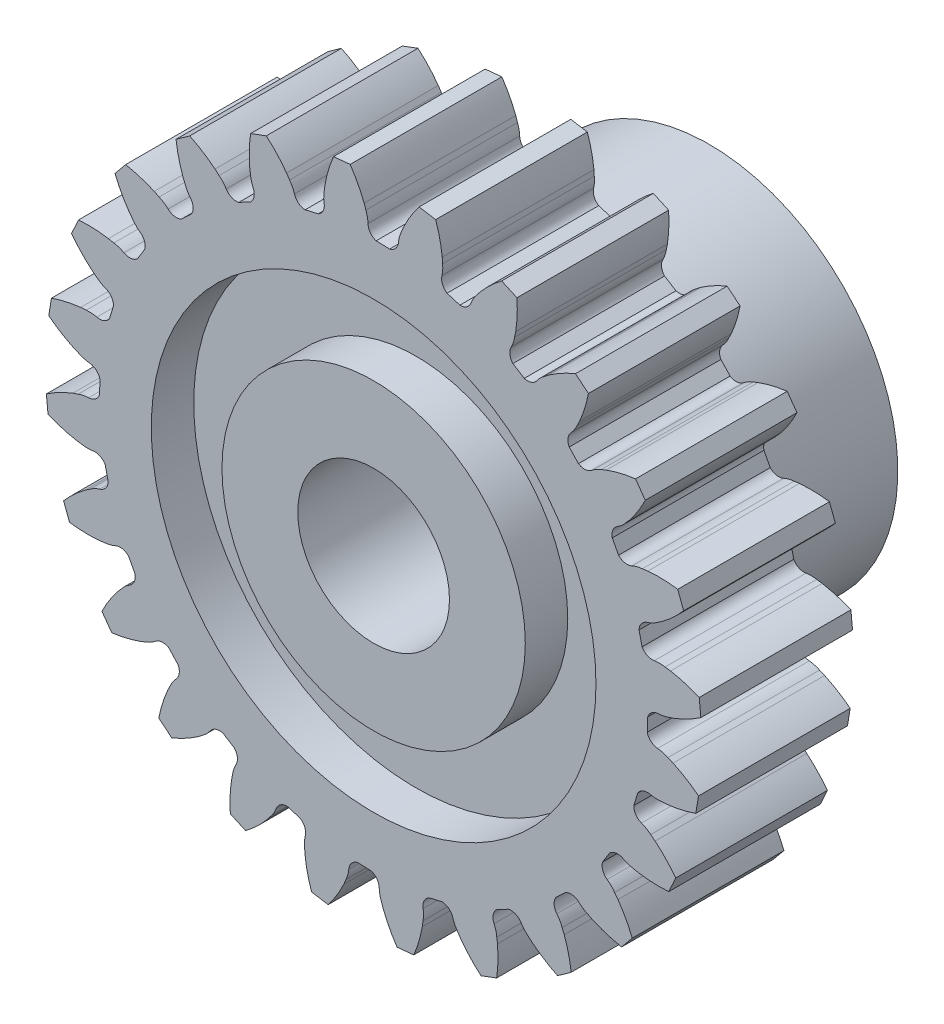
from build123d import *

# Parameters (mm, degrees)
MODEL_R             = 3.175
BOSS_EXTRUDE1_DEPTH = 6.35
SKETCH2_R           = 9.3091
SKETCH2_R_2         = 6.35
CUT_EXTRUDE1_DEPTH  = 1.778
SKETCH3_R           = 9.3091
CUT_EXTRUDE2_DEPTH  = 1.778
SKETCH4_R           = 7.8994
SKETCH4_R_2         = 3.175
BOSS_EXTRUDE2_DEPTH = 9.4742


with BuildPart() as part:
    # Model → Boss-Extrude1 (new body)
    with BuildSketch(Plane.XY):
        with BuildLine():
            Line((68.8088615, 76.100413011), (68.949845876, 76.283537584))
            ThreePointArc((68.949845876, 76.283537584), (69.380371663, 76.740716027), (69.860317621, 77.145705481))
            Line((69.860317621, 77.145705481), (70.499439483, 76.85531076))
            ThreePointArc((70.499439483, 76.85531076), (70.510066782, 76.227411927), (70.448876379, 75.602411432))
            Line((70.448876379, 75.602411432), (70.403671608, 75.375769654))
            ThreePointArc((70.403671608, 75.375769654), (70.351079825, 75.157164123), (70.262296035, 74.950592797))
            ThreePointArc((70.262296035, 74.950592797), (70.203912532, 74.656552674), (70.329513662, 74.384353958))
            Line((70.329513662, 74.384353958), (70.807027179, 74.086709545))
            ThreePointArc((70.807027179, 74.086709545), (71.106721458, 74.093816324), (71.345001962, 74.275721706))
            ThreePointArc((71.345001962, 74.275721706), (71.491362462, 74.446407496), (71.664470214, 74.58989593))
            Line((71.664470214, 74.58989593), (71.848050446, 74.730279746))
            ThreePointArc((71.848050446, 74.730279746), (72.382236404, 75.060455264), (72.950651667, 75.327428298))
            Line((72.950651667, 75.327428298), (73.492829056, 74.88151044))
            ThreePointArc((73.492829056, 74.88151044), (73.340582062, 74.272256193), (73.11971464, 73.684389315))
            Line((73.11971464, 73.684389315), (73.01739474, 73.477170567))
            ThreePointArc((73.01739474, 73.477170567), (72.910015705, 73.279625594), (72.770792556, 73.103071951))
            ThreePointArc((72.770792556, 73.103071951), (72.638293708, 72.834163378), (72.68915989, 72.538730092))
            Line((72.68915989, 72.538730092), (73.073367409, 72.127641188))
            ThreePointArc((73.073367409, 72.127641188), (73.364689222, 72.056939222), (73.641931092, 72.170974796))
            ThreePointArc((73.641931092, 72.170974796), (73.827484304, 72.297958978), (74.03183057, 72.391754283))
            Line((74.03183057, 72.391754283), (74.245486256, 72.479847735))
            ThreePointArc((74.245486256, 72.479847735), (74.846925351, 72.660513876), (75.46506923, 72.771272107))
            Line((75.46506923, 72.771272107), (75.873365539, 72.20022309))
            ThreePointArc((75.873365539, 72.20022309), (75.568619633, 71.6511331), (75.203126942, 71.140461996))
            Line((75.203126942, 71.140461996), (75.050655931, 70.966783028))
            ThreePointArc((75.050655931, 70.966783028), (74.895807345, 70.803760976), (74.715632665, 70.669256855))
            ThreePointArc((74.715632665, 70.669256855), (74.51805496, 70.443803566), (74.490728471, 70.145274966))
            Line((74.490728471, 70.145274966), (74.755440394, 69.648748496))
            ThreePointArc((74.755440394, 69.648748496), (75.018536642, 69.505056008), (75.315846303, 69.543450438))
            ThreePointArc((75.315846303, 69.543450438), (75.527943835, 69.618086964), (75.749605564, 69.655798184))
            Line((75.749605564, 69.655798184), (75.978779825, 69.685585753))
            ThreePointArc((75.978779825, 69.685585753), (76.606485613, 69.704433339), (77.232233636, 69.651431447))
            Line((77.232233636, 69.651431447), (77.478814431, 68.994162221))
            ThreePointArc((77.478814431, 68.994162221), (77.042337543, 68.542656063), (76.557127306, 68.143982124))
            Line((76.557127306, 68.143982124), (76.364907906, 68.015687086))
            ThreePointArc((76.364907906, 68.015687086), (76.173142447, 67.898297639), (75.964294842, 67.815009273))
            ThreePointArc((75.964294842, 67.815009273), (75.715093538, 67.648376021), (75.611430707, 67.367089736))
            Line((75.611430707, 67.367089736), (75.738616221, 66.818977076))
            ThreePointArc((75.738616221, 66.818977076), (75.955557329, 66.612086472), (76.252673618, 66.57222324))
            ThreePointArc((76.252673618, 66.57222324), (76.476858166, 66.589411997), (76.700722595, 66.568468))
            Line((76.700722595, 66.568468), (76.929808051, 66.537936887))
            ThreePointArc((76.929808051, 66.537936887), (77.540999679, 66.393678145), (78.131704169, 66.180525625))
            Line((78.131704169, 66.180525625), (78.199769385, 65.48183078))
            ThreePointArc((78.199769385, 65.48183078), (77.661306694, 65.158677853), (77.089445186, 64.899170049))
            Line((77.089445186, 64.899170049), (76.870569077, 64.824999283))
            ThreePointArc((76.870569077, 64.824999283), (76.654955242, 64.761242337), (76.431667331, 64.734845691))
            ThreePointArc((76.431667331, 64.734845691), (76.147830002, 64.638385436), (75.974903069, 64.393511046))
            Line((75.974903069, 64.393511046), (75.955890116, 63.83115471))
            ThreePointArc((75.955890116, 63.83115471), (76.111891907, 63.575165241), (76.38856684, 63.459760962))
            ThreePointArc((76.38856684, 63.459760962), (76.609564589, 63.418347349), (76.820382839, 63.340175925))
            Line((76.820382839, 63.340175925), (77.03375064, 63.251389295))
            ThreePointArc((77.03375064, 63.251389295), (77.586784215, 62.953859019), (78.102197554, 62.595084035))
            Line((78.102197554, 62.595084035), (77.987105718, 61.902581568))
            ThreePointArc((77.987105718, 61.902581568), (77.383352566, 61.729804209), (76.763811205, 61.627147569))
            Line((76.763811205, 61.627147569), (76.533196267, 61.61214822))
            ThreePointArc((76.533196267, 61.61214822), (76.308427784, 61.606368707), (76.08591627, 61.638662669))
            ThreePointArc((76.08591627, 61.638662669), (75.786787824, 61.618952841), (75.556371696, 61.427184945))
            Line((75.556371696, 61.427184945), (75.392458927, 60.888906711))
            ThreePointArc((75.392458927, 60.888906711), (75.476890135, 60.601263638), (75.714268773, 60.418182922))
            ThreePointArc((75.714268773, 60.418182922), (75.91701379, 60.320983054), (76.100413011, 60.190913432))
            Line((76.100413011, 60.190913432), (76.283537584, 60.049929057))
            ThreePointArc((76.283537584, 60.049929057), (76.740716361, 59.619399565), (77.145705481, 59.139449682))
            Line((77.145705481, 59.139449682), (76.85531076, 58.50033545))
            ThreePointArc((76.85531076, 58.50033545), (76.227411927, 58.489708151), (75.602411432, 58.550898554))
            Line((75.602411432, 58.550898554), (75.375769654, 58.59609951))
            ThreePointArc((75.375769654, 58.59609951), (75.157164123, 58.648691293), (74.950592797, 58.737475083))
            ThreePointArc((74.950592797, 58.737475083), (74.656552674, 58.795858586), (74.384353958, 58.670257456))
            Line((74.384353958, 58.670257456), (74.086709545, 58.192743939))
            ThreePointArc((74.086709545, 58.192743939), (74.093816324, 57.893049661), (74.275721706, 57.654769156))
            ThreePointArc((74.275721706, 57.654769156), (74.446407496, 57.508408656), (74.58989593, 57.335300904))
            Line((74.58989593, 57.335300904), (74.730279746, 57.151724487))
            ThreePointArc((74.730279746, 57.151724487), (75.060455264, 56.617538528), (75.327428298, 56.049123266))
            Line((75.327428298, 56.049123266), (74.88151044, 55.506945877))
            ThreePointArc((74.88151044, 55.506945877), (74.272256193, 55.65919287), (73.684389315, 55.880060293))
            Line((73.684389315, 55.880060293), (73.477170567, 55.982380192))
            ThreePointArc((73.477170567, 55.982380192), (73.279625594, 56.089759228), (73.103071951, 56.228982377))
            ThreePointArc((73.103071951, 56.228982377), (72.834161527, 56.361479387), (72.538730092, 56.310607414))
            Line((72.538730092, 56.310607414), (72.127641188, 55.926399894))
            ThreePointArc((72.127641188, 55.926399894), (72.056939222, 55.635078081), (72.170974796, 55.357836211))
            ThreePointArc((72.170974796, 55.357836211), (72.297959706, 55.172285528), (72.391754283, 54.967940548))
            Line((72.391754283, 54.967940548), (72.479847735, 54.754284862))
            ThreePointArc((72.479847735, 54.754284862), (72.660513876, 54.152845767), (72.771272107, 53.534701888))
            Line((72.771272107, 53.534701888), (72.20022309, 53.126409394))
            ThreePointArc((72.20022309, 53.126409394), (71.6511331, 53.4311553), (71.140461996, 53.796647991))
            Line((71.140461996, 53.796647991), (70.966783028, 53.949115187))
            ThreePointArc((70.966783028, 53.949115187), (70.803760976, 54.103963773), (70.669256855, 54.284138453))
            ThreePointArc((70.669256855, 54.284138453), (70.443804302, 54.481717533), (70.145274966, 54.509046462))
            Line((70.145274966, 54.509046462), (69.648748496, 54.244326909))
            ThreePointArc((69.648748496, 54.244326909), (69.505056008, 53.981230662), (69.543450438, 53.683921001))
            ThreePointArc((69.543450438, 53.683921001), (69.618087836, 53.471827731), (69.655798184, 53.250169369))
            Line((69.655798184, 53.250169369), (69.685585753, 53.020991294))
            ThreePointArc((69.685585753, 53.020991294), (69.704433339, 52.393285505), (69.651431447, 51.767537482))
            Line((69.651431447, 51.767537482), (68.994162221, 51.520956687))
            ThreePointArc((68.994162221, 51.520956687), (68.542656063, 51.957433575), (68.143982124, 52.442643812))
            Line((68.143982124, 52.442643812), (68.015687086, 52.634867027))
            ThreePointArc((68.015687086, 52.634867027), (67.898297639, 52.826632486), (67.815009273, 53.035480091))
            ThreePointArc((67.815009273, 53.035480091), (67.648375221, 53.284679531), (67.367089736, 53.388340411))
            Line((67.367089736, 53.388340411), (66.818977076, 53.261151082))
            ThreePointArc((66.818977076, 53.261151082), (66.612086472, 53.044209975), (66.57222324, 52.747093685))
            ThreePointArc((66.57222324, 52.747093685), (66.589411997, 52.522909138), (66.568468, 52.299044708))
            Line((66.568468, 52.299044708), (66.537936887, 52.069966882))
            ThreePointArc((66.537936887, 52.069966882), (66.393678566, 51.458771379), (66.180525625, 50.868063135))
            Line((66.180525625, 50.868063135), (65.48183078, 50.799997919))
            ThreePointArc((65.48183078, 50.799997919), (65.158677853, 51.33846061), (64.899170049, 51.910322117))
            Line((64.899170049, 51.910322117), (64.824999283, 52.129202042))
            ThreePointArc((64.824999283, 52.129202042), (64.761242337, 52.344815876), (64.734845691, 52.568103787))
            ThreePointArc((64.734845691, 52.568103787), (64.638386536, 52.851943372), (64.393511046, 53.024871864))
            Line((64.393511046, 53.024871864), (63.83115471, 53.043877187))
            ThreePointArc((63.83115471, 53.043877187), (63.575165241, 52.887875397), (63.459760962, 52.611200463))
            ThreePointArc((63.459760962, 52.611200463), (63.418346843, 52.390204701), (63.340175925, 52.179388279))
            Line((63.340175925, 52.179388279), (63.251389295, 51.966020478))
            ThreePointArc((63.251389295, 51.966020478), (62.953859019, 51.412986904), (62.595084035, 50.897573564))
            Line((62.595084035, 50.897573564), (61.902581568, 51.0126654))
            ThreePointArc((61.902581568, 51.0126654), (61.729804209, 51.616418552), (61.627147569, 52.235959913))
            Line((61.627147569, 52.235959913), (61.61214822, 52.466574851))
            ThreePointArc((61.61214822, 52.466574851), (61.606368707, 52.691343334), (61.638662669, 52.913854848))
            ThreePointArc((61.638662669, 52.913854848), (61.618954398, 53.212985739), (61.427184945, 53.443403236))
            Line((61.427184945, 53.443403236), (60.888906711, 53.607312192))
            ThreePointArc((60.888906711, 53.607312192), (60.601263638, 53.522880983), (60.418182922, 53.285502345))
            ThreePointArc((60.418182922, 53.285502345), (60.320983959, 53.08275505), (60.190913432, 52.899354292))
            Line((60.190913432, 52.899354292), (60.049929057, 52.716237349))
            ThreePointArc((60.049929057, 52.716237349), (59.619399888, 52.259054647), (59.139449682, 51.854061822))
            Line((59.139449682, 51.854061822), (58.50033545, 52.144460358))
            ThreePointArc((58.50033545, 52.144460358), (58.489708151, 52.772359191), (58.550898554, 53.397359686))
            Line((58.550898554, 53.397359686), (58.59609951, 53.624001464))
            ThreePointArc((58.59609951, 53.624001464), (58.648691293, 53.842606995), (58.737475083, 54.049178321))
            ThreePointArc((58.737475083, 54.049178321), (58.795858586, 54.343218445), (58.670257456, 54.61541716))
            Line((58.670257456, 54.61541716), (58.192743939, 54.913057758))
            ThreePointArc((58.192743939, 54.913057758), (57.893049661, 54.90595098), (57.654769156, 54.724045598))
            ThreePointArc((57.654769156, 54.724045598), (57.508406449, 54.553365266), (57.335300904, 54.409879003))
            Line((57.335300904, 54.409879003), (57.151724487, 54.269487558))
            ThreePointArc((57.151724487, 54.269487558), (56.617538528, 53.93931204), (56.049123266, 53.672339006))
            Line((56.049123266, 53.672339006), (55.506945877, 54.118260679))
            ThreePointArc((55.506945877, 54.118260679), (55.65919287, 54.727514925), (55.880060293, 55.315381803))
            Line((55.880060293, 55.315381803), (55.982380192, 55.522600551))
            ThreePointArc((55.982380192, 55.522600551), (56.089759228, 55.720145524), (56.228982377, 55.896699167))
            ThreePointArc((56.228982377, 55.896699167), (56.361479387, 56.165609591), (56.310607414, 56.461041026))
            Line((56.310607414, 56.461041026), (55.926399894, 56.87212993))
            ThreePointArc((55.926399894, 56.87212993), (55.635078081, 56.942831896), (55.357836211, 56.828796322))
            ThreePointArc((55.357836211, 56.828796322), (55.172285528, 56.701811412), (54.967940548, 56.608016835))
            Line((54.967940548, 56.608016835), (54.754284862, 56.519923383))
            ThreePointArc((54.754284862, 56.519923383), (54.152845767, 56.339257242), (53.534701888, 56.228499012))
            Line((53.534701888, 56.228499012), (53.126409394, 56.799551843))
            ThreePointArc((53.126409394, 56.799551843), (53.4311553, 57.348641833), (53.796647991, 57.859312937))
            Line((53.796647991, 57.859312937), (53.949115187, 58.03298809))
            ThreePointArc((53.949115187, 58.03298809), (54.103963773, 58.196010142), (54.284138453, 58.330514263))
            ThreePointArc((54.284138453, 58.330514263), (54.48172016, 58.555968441), (54.509046462, 58.854499967))
            Line((54.509046462, 58.854499967), (54.244326909, 59.351018807))
            ThreePointArc((54.244326909, 59.351018807), (53.981230662, 59.494711295), (53.683921001, 59.456316866))
            ThreePointArc((53.683921001, 59.456316866), (53.471826215, 59.381686704), (53.250169369, 59.343976749))
            Line((53.250169369, 59.343976749), (53.020991294, 59.31418155))
            ThreePointArc((53.020991294, 59.31418155), (52.393285395, 59.295335869), (51.767537482, 59.348339671))
            Line((51.767537482, 59.348339671), (51.520956687, 60.005605082))
            ThreePointArc((51.520956687, 60.005605082), (51.957433575, 60.45711124), (52.442643812, 60.855785179))
            Line((52.442643812, 60.855785179), (52.634867027, 60.984084032))
            ThreePointArc((52.634867027, 60.984084032), (52.826632486, 61.10147348), (53.035480091, 61.184761845))
            ThreePointArc((53.035480091, 61.184761845), (53.284679531, 61.351395898), (53.388340411, 61.632681382))
            Line((53.388340411, 61.632681382), (53.261151082, 62.180797857))
            ThreePointArc((53.261151082, 62.180797857), (53.044209975, 62.387688461), (52.747093685, 62.427551693))
            ThreePointArc((52.747093685, 62.427551693), (52.522909751, 62.410355302), (52.299044708, 62.431299304))
            Line((52.299044708, 62.431299304), (52.069966882, 62.461838046))
            ThreePointArc((52.069966882, 62.461838046), (51.458771379, 62.606096367), (50.868063135, 62.819249308))
            Line((50.868063135, 62.819249308), (50.799997919, 63.517936523))
            ThreePointArc((50.799997919, 63.517936523), (51.33846061, 63.841089451), (51.910322117, 64.100597254))
            Line((51.910322117, 64.100597254), (52.129202042, 64.17477565))
            ThreePointArc((52.129202042, 64.17477565), (52.344815876, 64.238532596), (52.568103787, 64.264929241))
            ThreePointArc((52.568103787, 64.264929241), (52.851941109, 64.361387652), (53.024871864, 64.606260072))
            Line((53.024871864, 64.606260072), (53.043877187, 65.168616408))
            ThreePointArc((53.043877187, 65.168616408), (52.887875397, 65.424605877), (52.611200463, 65.540010156))
            ThreePointArc((52.611200463, 65.540010156), (52.390204701, 65.581424276), (52.179388279, 65.659595193))
            Line((52.179388279, 65.659595193), (51.966020478, 65.748385638))
            ThreePointArc((51.966020478, 65.748385638), (51.412986904, 66.045915914), (50.897573564, 66.404690898))
            Line((50.897573564, 66.404690898), (51.0126654, 67.09718955))
            ThreePointArc((51.0126654, 67.09718955), (51.616418552, 67.269966909), (52.235959913, 67.37262355))
            Line((52.235959913, 67.37262355), (52.466574851, 67.387622898))
            ThreePointArc((52.466574851, 67.387622898), (52.691343334, 67.393402412), (52.913854848, 67.361108449))
            ThreePointArc((52.913854848, 67.361108449), (53.212985739, 67.38081672), (53.443403236, 67.572586174))
            Line((53.443403236, 67.572586174), (53.607312192, 68.110860592))
            ThreePointArc((53.607312192, 68.110860592), (53.522880983, 68.398503666), (53.285502345, 68.581584382))
            ThreePointArc((53.285502345, 68.581584382), (53.082756215, 68.678790288), (52.899354292, 68.8088615))
            Line((52.899354292, 68.8088615), (52.716237349, 68.949845876))
            ThreePointArc((52.716237349, 68.949845876), (52.259054982, 69.38037134), (51.854061822, 69.860317621))
            Line((51.854061822, 69.860317621), (52.144460358, 70.499439483))
            ThreePointArc((52.144460358, 70.499439483), (52.772359191, 70.510066782), (53.397359686, 70.448876379))
            Line((53.397359686, 70.448876379), (53.624001464, 70.403671608))
            ThreePointArc((53.624001464, 70.403671608), (53.842606995, 70.351079825), (54.049178321, 70.262296035))
            ThreePointArc((54.049178321, 70.262296035), (54.343218445, 70.203912532), (54.61541716, 70.329513662))
            Line((54.61541716, 70.329513662), (54.913057758, 70.807027179))
            ThreePointArc((54.913057758, 70.807027179), (54.90595098, 71.106721458), (54.724045598, 71.345001962))
            ThreePointArc((54.724045598, 71.345001962), (54.553365266, 71.491364669), (54.409879003, 71.664470214))
            Line((54.409879003, 71.664470214), (54.269487558, 71.848050446))
            ThreePointArc((54.269487558, 71.848050446), (53.93931204, 72.382236404), (53.672339006, 72.950651667))
            Line((53.672339006, 72.950651667), (54.118260679, 73.492829056))
            ThreePointArc((54.118260679, 73.492829056), (54.727514925, 73.340582062), (55.315381803, 73.11971464))
            Line((55.315381803, 73.11971464), (55.522600551, 73.01739474))
            ThreePointArc((55.522600551, 73.01739474), (55.720145524, 72.910015705), (55.896699167, 72.770792556))
            ThreePointArc((55.896699167, 72.770792556), (56.16560774, 72.638293708), (56.461041026, 72.68915989))
            Line((56.461041026, 72.68915989), (56.87212993, 73.073367409))
            ThreePointArc((56.87212993, 73.073367409), (56.942831896, 73.364689222), (56.828796322, 73.641931092))
            ThreePointArc((56.828796322, 73.641931092), (56.70181214, 73.827484304), (56.608016835, 74.03183057))
            Line((56.608016835, 74.03183057), (56.519923383, 74.245486256))
            ThreePointArc((56.519923383, 74.245486256), (56.339257242, 74.846925351), (56.228499012, 75.46506923))
            Line((56.228499012, 75.46506923), (56.799551843, 75.873365539))
            ThreePointArc((56.799551843, 75.873365539), (57.348641833, 75.568619633), (57.859312937, 75.203126942))
            Line((57.859312937, 75.203126942), (58.03298809, 75.050655931))
            ThreePointArc((58.03298809, 75.050655931), (58.196010142, 74.895807345), (58.330514263, 74.715632665))
            ThreePointArc((58.330514263, 74.715632665), (58.555969178, 74.518052333), (58.854499967, 74.490728471))
            Line((58.854499967, 74.490728471), (59.351018807, 74.755440394))
            ThreePointArc((59.351018807, 74.755440394), (59.494711295, 75.018536642), (59.456316866, 75.315846303))
            ThreePointArc((59.456316866, 75.315846303), (59.381687576, 75.527945351), (59.343976749, 75.749605564))
            Line((59.343976749, 75.749605564), (59.31418155, 75.978779825))
            ThreePointArc((59.31418155, 75.978779825), (59.295335869, 76.606485723), (59.348339671, 77.232233636))
            Line((59.348339671, 77.232233636), (60.005605082, 77.478814431))
            ThreePointArc((60.005605082, 77.478814431), (60.45711124, 77.042337543), (60.855785179, 76.557127306))
            Line((60.855785179, 76.557127306), (60.984084032, 76.364907906))
            ThreePointArc((60.984084032, 76.364907906), (61.10147348, 76.173142447), (61.184761845, 75.964294842))
            ThreePointArc((61.184761845, 75.964294842), (61.351395097, 75.715093538), (61.632681382, 75.611430707))
            Line((61.632681382, 75.611430707), (62.180797857, 75.738616221))
            ThreePointArc((62.180797857, 75.738616221), (62.387688461, 75.955557329), (62.427551693, 76.252673618))
            ThreePointArc((62.427551693, 76.252673618), (62.410355302, 76.476857552), (62.431299304, 76.700722595))
            Line((62.431299304, 76.700722595), (62.461838046, 76.929808051))
            ThreePointArc((62.461838046, 76.929808051), (62.606096788, 77.540999679), (62.819249308, 78.131704169))
            Line((62.819249308, 78.131704169), (63.517936523, 78.199769385))
            ThreePointArc((63.517936523, 78.199769385), (63.841089451, 77.661306694), (64.100597254, 77.089445186))
            Line((64.100597254, 77.089445186), (64.17477565, 76.870569077))
            ThreePointArc((64.17477565, 76.870569077), (64.238532596, 76.654955242), (64.264929241, 76.431667331))
            ThreePointArc((64.264929241, 76.431667331), (64.361388753, 76.147832265), (64.606260072, 75.974903069))
            Line((64.606260072, 75.974903069), (65.168616408, 75.955890116))
            ThreePointArc((65.168616408, 75.955890116), (65.424605877, 76.111891907), (65.540010156, 76.38856684))
            ThreePointArc((65.540010156, 76.38856684), (65.581423769, 76.609564589), (65.659595193, 76.820382839))
            Line((65.659595193, 76.820382839), (65.748385638, 77.03375064))
            ThreePointArc((65.748385638, 77.03375064), (66.045915914, 77.586784215), (66.404690898, 78.102197554))
            Line((66.404690898, 78.102197554), (67.09718955, 77.987105718))
            ThreePointArc((67.09718955, 77.987105718), (67.269966909, 77.383352566), (67.37262355, 76.763811205))
            Line((67.37262355, 76.763811205), (67.387622898, 76.533196267))
            ThreePointArc((67.387622898, 76.533196267), (67.393402412, 76.308427784), (67.361108449, 76.08591627))
            ThreePointArc((67.361108449, 76.08591627), (67.380818277, 75.786787824), (67.572586174, 75.556371696))
            Line((67.572586174, 75.556371696), (68.110860592, 75.392458927))
            ThreePointArc((68.110860592, 75.392458927), (68.398503666, 75.476890135), (68.581584382, 75.714268773))
            ThreePointArc((68.581584382, 75.714268773), (68.678791193, 75.917012626), (68.8088615, 76.100413011))
        make_face()
        with Locations((64.499885559, 64.499885559)):
            Circle(MODEL_R, mode=Mode.SUBTRACT)
    extrude(amount=BOSS_EXTRUDE1_DEPTH)

    # Sketch2 → Cut-Extrude1 (cut)
    with BuildSketch(Plane.XY.offset(6.35)):
        with Locations((64.499885559, 64.499885559)):
            Circle(SKETCH2_R)
        with Locations((64.499885559, 64.499885559)):
            Circle(SKETCH2_R_2, mode=Mode.SUBTRACT)
    extrude(amount=-CUT_EXTRUDE1_DEPTH, mode=Mode.SUBTRACT)

    # Sketch3 → Cut-Extrude2 (cut)
    with BuildSketch(Plane(origin=(0, 0, 0), x_dir=(-1, 0, 0), z_dir=(0, 0, -1))):
        with Locations(Location((-64.499885559, 64.499885559, 0), (0, 0, 180))):  # turned: the seam where the file's is
            Circle(SKETCH3_R)
    extrude(amount=-CUT_EXTRUDE2_DEPTH, mode=Mode.SUBTRACT)

    # Sketch4 → Boss-Extrude2 (add)
    with BuildSketch(Plane(origin=(0, 0, 1.778), x_dir=(-1, 0, 0), z_dir=(0, 0, -1))):
        with Locations((-64.499885559, 64.499885559)):
            Circle(SKETCH4_R)
        with Locations((-64.499885559, 64.499885559)):
            Circle(SKETCH4_R_2, mode=Mode.SUBTRACT)
    extrude(amount=BOSS_EXTRUDE2_DEPTH)


solid = part.part
